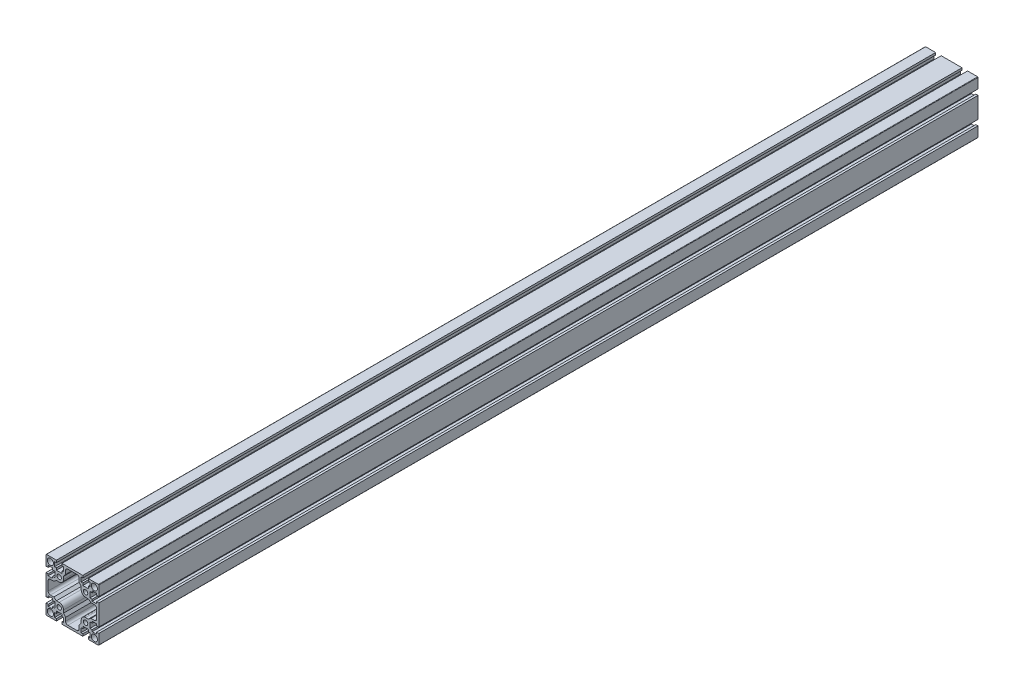
from build123d import *

# Parameters (mm, degrees)
SKETCH_1_R      = 3.5
SKETCH_1_R_2    = 2.5
EXTRUDE_1_DEPTH = 1000


with BuildPart() as part:
    # Эскиз1 → Бобышка-Вытянуть1 (new body)
    with BuildSketch(Plane.XY):
        with BuildLine():
            Line((-30, 20.15), (-30, 29.5))
            ThreePointArc((-30, 29.5), (-29.853553391, 29.853553391), (-29.5, 30))
            Line((-29.5, 30), (-20.15, 30))
            Line((-20.15, 30), (-18.15, 30))
            Line((-18.15, 30), (-18.15, 27.5))
            Line((-18.15, 27.5), (-20.15, 27.5))
            Line((-20.15, 27.5), (-20.15, 22.5))
            Line((-20.15, 22.5), (-18.15, 22.5))
            Line((-18.15, 22.5), (-18.15, 20))
            Line((-18.15, 20), (-11.85, 20))
            Line((-11.85, 20), (-11.85, 22.5))
            Line((-11.85, 22.5), (-9.85, 22.5))
            Line((-9.85, 22.5), (-9.85, 27.5))
            Line((-9.85, 27.5), (-11.85, 27.5))
            Line((-11.85, 27.5), (-11.85, 30))
            Line((-11.85, 30), (-9.85, 30))
            Line((-9.85, 30), (0, 30))
            Line((0, 30), (9.85, 30))
            Line((9.85, 30), (11.85, 30))
            Line((11.85, 30), (11.85, 27.5))
            Line((11.85, 27.5), (9.85, 27.5))
            Line((9.85, 27.5), (9.85, 22.5))
            Line((9.85, 22.5), (11.85, 22.5))
            Line((11.85, 22.5), (11.85, 20))
            Line((11.85, 20), (18.15, 20))
            Line((18.15, 20), (18.15, 22.5))
            Line((18.15, 22.5), (20.15, 22.5))
            Line((20.15, 22.5), (20.15, 27.5))
            Line((20.15, 27.5), (18.15, 27.5))
            Line((18.15, 27.5), (18.15, 30))
            Line((18.15, 30), (20.15, 30))
            Line((20.15, 30), (29.5, 30))
            ThreePointArc((29.5, 30), (29.853553391, 29.853553391), (30, 29.5))
            Line((30, 29.5), (30, 20.15))
            Line((30, 20.15), (30, 18.15))
            Line((30, 18.15), (27.5, 18.15))
            Line((27.5, 18.15), (27.5, 20.15))
            Line((27.5, 20.15), (22.5, 20.15))
            Line((22.5, 20.15), (22.5, 18.15))
            Line((22.5, 18.15), (20, 18.15))
            Line((20, 18.15), (20, 11.85))
            Line((20, 11.85), (22.5, 11.85))
            Line((22.5, 11.85), (22.5, 9.85))
            Line((22.5, 9.85), (27.5, 9.85))
            Line((27.5, 9.85), (27.5, 11.85))
            Line((27.5, 11.85), (30, 11.85))
            Line((30, 11.85), (30, 9.85))
            Line((30, 9.85), (30, 0))
            Line((30, 0), (30, -9.85))
            Line((30, -9.85), (30, -11.85))
            Line((30, -11.85), (27.5, -11.85))
            Line((27.5, -11.85), (27.5, -9.85))
            Line((27.5, -9.85), (22.5, -9.85))
            Line((22.5, -9.85), (22.5, -11.85))
            Line((22.5, -11.85), (20, -11.85))
            Line((20, -11.85), (20, -18.15))
            Line((20, -18.15), (22.5, -18.15))
            Line((22.5, -18.15), (22.5, -20.15))
            Line((22.5, -20.15), (27.5, -20.15))
            Line((27.5, -20.15), (27.5, -18.15))
            Line((27.5, -18.15), (30, -18.15))
            Line((30, -18.15), (30, -20.15))
            Line((30, -20.15), (30, -29.5))
            ThreePointArc((30, -29.5), (29.853553391, -29.853553391), (29.5, -30))
            Line((29.5, -30), (20.15, -30))
            Line((20.15, -30), (18.15, -30))
            Line((18.15, -30), (18.15, -27.5))
            Line((18.15, -27.5), (20.15, -27.5))
            Line((20.15, -27.5), (20.15, -22.5))
            Line((20.15, -22.5), (18.15, -22.5))
            Line((18.15, -22.5), (18.15, -20))
            Line((18.15, -20), (11.85, -20))
            Line((11.85, -20), (11.85, -22.5))
            Line((11.85, -22.5), (9.85, -22.5))
            Line((9.85, -22.5), (9.85, -27.5))
            Line((9.85, -27.5), (11.85, -27.5))
            Line((11.85, -27.5), (11.85, -30))
            Line((11.85, -30), (9.85, -30))
            Line((9.85, -30), (0, -30))
            Line((0, -30), (-9.85, -30))
            Line((-9.85, -30), (-11.85, -30))
            Line((-11.85, -30), (-11.85, -27.5))
            Line((-11.85, -27.5), (-9.85, -27.5))
            Line((-9.85, -27.5), (-9.85, -22.5))
            Line((-9.85, -22.5), (-11.85, -22.5))
            Line((-11.85, -22.5), (-11.85, -20))
            Line((-11.85, -20), (-18.15, -20))
            Line((-18.15, -20), (-18.15, -22.5))
            Line((-18.15, -22.5), (-20.15, -22.5))
            Line((-20.15, -22.5), (-20.15, -27.5))
            Line((-20.15, -27.5), (-18.15, -27.5))
            Line((-18.15, -27.5), (-18.15, -30))
            Line((-18.15, -30), (-20.15, -30))
            Line((-20.15, -30), (-29.5, -30))
            ThreePointArc((-29.5, -30), (-29.853553391, -29.853553391), (-30, -29.5))
            Line((-30, -29.5), (-30, -20.15))
            Line((-30, -20.15), (-30, -18.15))
            Line((-30, -18.15), (-27.5, -18.15))
            Line((-27.5, -18.15), (-27.5, -20.15))
            Line((-27.5, -20.15), (-22.5, -20.15))
            Line((-22.5, -20.15), (-22.5, -18.15))
            Line((-22.5, -18.15), (-20, -18.15))
            Line((-20, -18.15), (-20, -11.85))
            Line((-20, -11.85), (-22.5, -11.85))
            Line((-22.5, -11.85), (-22.5, -9.85))
            Line((-22.5, -9.85), (-27.5, -9.85))
            Line((-27.5, -9.85), (-27.5, -11.85))
            Line((-27.5, -11.85), (-30, -11.85))
            Line((-30, -11.85), (-30, -9.85))
            Line((-30, -9.85), (-30, 0))
            Line((-30, 0), (-30, 9.85))
            Line((-30, 9.85), (-30, 11.85))
            Line((-30, 11.85), (-27.5, 11.85))
            Line((-27.5, 11.85), (-27.5, 9.85))
            Line((-27.5, 9.85), (-22.5, 9.85))
            Line((-22.5, 9.85), (-22.5, 11.85))
            Line((-22.5, 11.85), (-20, 11.85))
            Line((-20, 11.85), (-20, 18.15))
            Line((-20, 18.15), (-22.5, 18.15))
            Line((-22.5, 18.15), (-22.5, 20.15))
            Line((-22.5, 20.15), (-27.5, 20.15))
            Line((-27.5, 20.15), (-27.5, 18.15))
            Line((-27.5, 18.15), (-30, 18.15))
            Line((-30, 18.15), (-30, 20.15))
        make_face()
        with Locations((-25, 25)):
            Circle(SKETCH_1_R, mode=Mode.SUBTRACT)
        with Locations((-15, 15)):
            Circle(SKETCH_1_R_2, mode=Mode.SUBTRACT)
        with Locations((25, 25)):
            Circle(SKETCH_1_R, mode=Mode.SUBTRACT)
        with Locations((15, 15)):
            Circle(SKETCH_1_R_2, mode=Mode.SUBTRACT)
        with Locations((25, -25)):
            Circle(SKETCH_1_R, mode=Mode.SUBTRACT)
        with Locations((15, -15)):
            Circle(SKETCH_1_R_2, mode=Mode.SUBTRACT)
        with Locations((-25, -25)):
            Circle(SKETCH_1_R, mode=Mode.SUBTRACT)
        with Locations((-15, -15)):
            Circle(SKETCH_1_R_2, mode=Mode.SUBTRACT)
        with BuildLine():
            Line((0, 27.6), (-5.15, 27.6))
            ThreePointArc((-5.15, 27.6), (-6.988477631, 26.838477631), (-7.75, 25))
            Line((-7.75, 25), (-7.75, 21.1))
            Line((-7.75, 21.1), (-10, 18.1))
            Line((-10, 18.1), (-10, 15))
            ThreePointArc((-10, 15), (-11.464466094, 11.464466094), (-15, 10))
            Line((-15, 10), (-18.1, 10))
            Line((-18.1, 10), (-21.1, 7.75))
            Line((-21.1, 7.75), (-25, 7.75))
            ThreePointArc((-25, 7.75), (-26.838477631, 6.988477631), (-27.6, 5.15))
            Line((-27.6, 5.15), (-27.6, 0))
            Line((-27.6, 0), (-27.6, -5.15))
            ThreePointArc((-27.6, -5.15), (-26.838477631, -6.988477631), (-25, -7.75))
            Line((-25, -7.75), (-21.1, -7.75))
            Line((-21.1, -7.75), (-18.1, -10))
            Line((-18.1, -10), (-15, -10))
            ThreePointArc((-15, -10), (-11.464466094, -11.464466094), (-10, -15))
            Line((-10, -15), (-10, -18.1))
            Line((-10, -18.1), (-7.75, -21.1))
            Line((-7.75, -21.1), (-7.75, -25))
            ThreePointArc((-7.75, -25), (-6.988477631, -26.838477631), (-5.15, -27.6))
            Line((-5.15, -27.6), (0, -27.6))
            Line((0, -27.6), (5.15, -27.6))
            ThreePointArc((5.15, -27.6), (6.988477631, -26.838477631), (7.75, -25))
            Line((7.75, -25), (7.75, -21.1))
            Line((7.75, -21.1), (10, -18.1))
            Line((10, -18.1), (10, -15))
            ThreePointArc((10, -15), (11.464466094, -11.464466094), (15, -10))
            Line((15, -10), (18.1, -10))
            Line((18.1, -10), (21.1, -7.75))
            Line((21.1, -7.75), (25, -7.75))
            ThreePointArc((25, -7.75), (26.838477631, -6.988477631), (27.6, -5.15))
            Line((27.6, -5.15), (27.6, 0))
            Line((27.6, 0), (27.6, 5.15))
            ThreePointArc((27.6, 5.15), (26.838477631, 6.988477631), (25, 7.75))
            Line((25, 7.75), (21.1, 7.75))
            Line((21.1, 7.75), (18.1, 10))
            Line((18.1, 10), (15, 10))
            ThreePointArc((15, 10), (11.464466094, 11.464466094), (10, 15))
            Line((10, 15), (10, 18.1))
            Line((10, 18.1), (7.75, 21.1))
            Line((7.75, 21.1), (7.75, 25))
            ThreePointArc((7.75, 25), (6.988477631, 26.838477631), (5.15, 27.6))
            Line((5.15, 27.6), (0, 27.6))
        make_face(mode=Mode.SUBTRACT)
    extrude(amount=EXTRUDE_1_DEPTH)


solid = part.part
